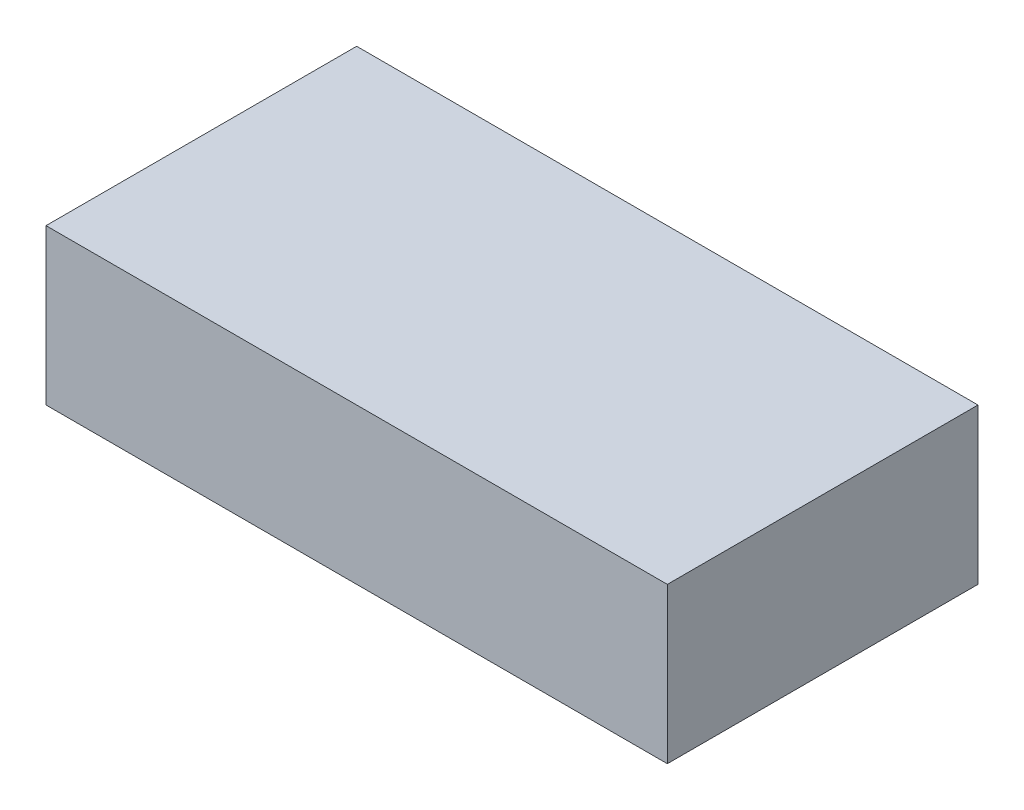
from build123d import *

# Parameters (mm, degrees)
ESQUISSE1_W      = 2
ESQUISSE1_H      = 1
EXTRUSION1_DEPTH = 0.5


with BuildPart() as part:
    # Esquisse1 → Extrusion1 (new body)
    with BuildSketch(Plane(origin=(0, 0, 0), x_dir=(1, 0, 0), z_dir=(0, 1, 0))):
        with Locations((1, 0.5)):
            Rectangle(ESQUISSE1_W, ESQUISSE1_H)
    extrude(amount=EXTRUSION1_DEPTH)


solid = part.part
